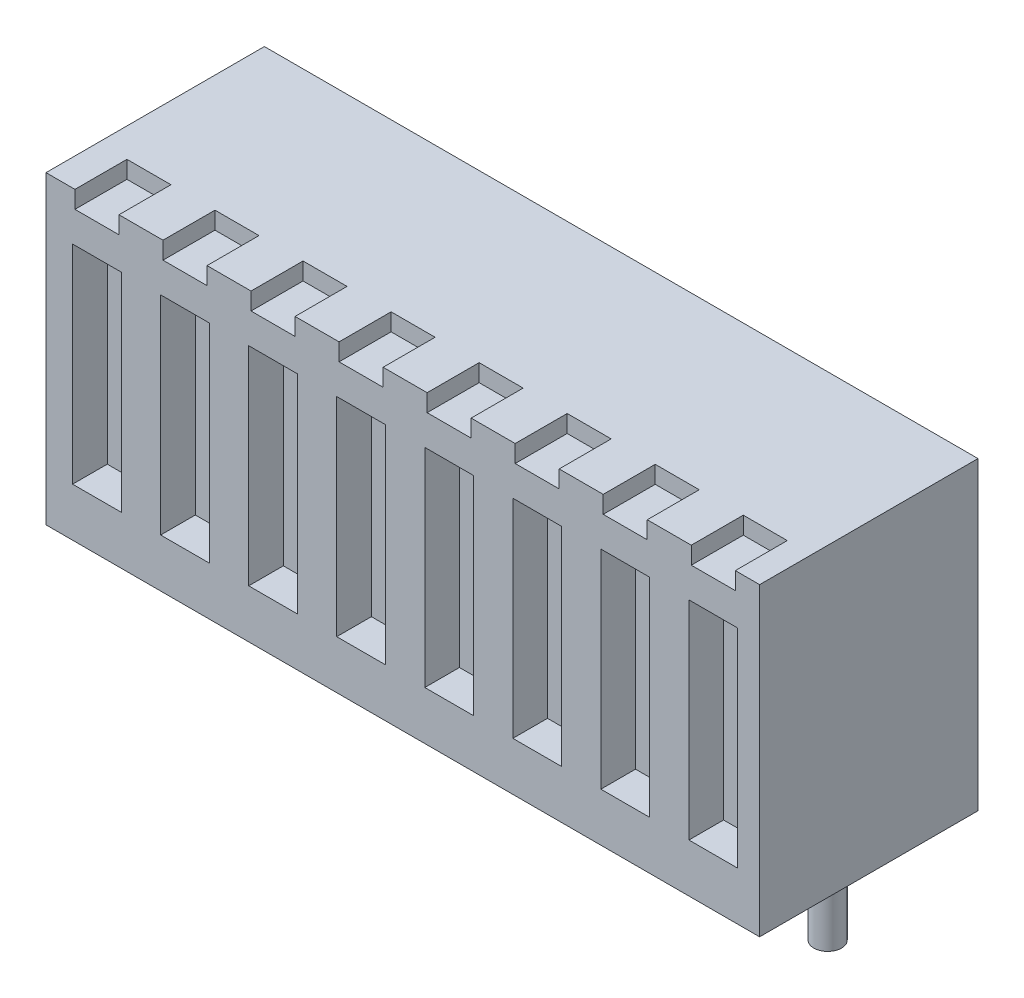
from build123d import *

# Parameters (mm, degrees)
SKETCH2_W           = 20.586666666
SKETCH2_H           = 6.3
BOSS_EXTRUDE1_DEPTH = 8.8
SKETCH3_R           = 0.4
BOSS_EXTRUDE2_DEPTH = 2.4
SKETCH4_W           = 1.405361948
SKETCH4_H           = 6
CUT_EXTRUDE1_DEPTH  = 1
SKETCH5_W           = 1.27
SKETCH5_H           = 1.5
CUT_EXTRUDE2_DEPTH  = 0.5
LPATTERN1_COUNT     = 8
LPATTERN1_PITCH     = 2.54


with BuildPart() as part:
    # Sketch2 → Boss-Extrude1 (new body)
    with BuildSketch(Plane(origin=(0, 0, 0), x_dir=(1, 0, 0), z_dir=(0, 1, 0))):
        Rectangle(SKETCH2_W, SKETCH2_H)
    extrude(amount=BOSS_EXTRUDE1_DEPTH)

    # Sketch3 → Boss-Extrude2 (add)
    with BuildSketch(Plane.XZ):
        with Locations((-8.823333333, -0.15)):
            Circle(SKETCH3_R)
    boss_extrude2 = extrude(amount=BOSS_EXTRUDE2_DEPTH)

    # Sketch4 → Cut-Extrude1 (cut)
    with BuildSketch(Plane.XY.offset(3.15)):
        with Locations((-8.823333333, 4.4)):
            Rectangle(SKETCH4_W, SKETCH4_H)
    cut_extrude1 = extrude(amount=-CUT_EXTRUDE1_DEPTH, mode=Mode.SUBTRACT)

    # Sketch5 → Cut-Extrude2 (cut)
    with BuildSketch(Plane(origin=(0, 8.8, 0), x_dir=(1, 0, 0), z_dir=(0, 1, 0))):
        with Locations((-8.823333333, -2.4)):
            Rectangle(SKETCH5_W, SKETCH5_H)
    cut_extrude2 = extrude(amount=-CUT_EXTRUDE2_DEPTH, mode=Mode.SUBTRACT)

    # LPattern1: Boss-Extrude2, Cut-Extrude1, Cut-Extrude2 ×8
    with Locations(*[(i * LPATTERN1_PITCH, 0, 0) for i in range(1, LPATTERN1_COUNT)]):
        add(boss_extrude2)
        add(cut_extrude1, mode=Mode.SUBTRACT)
        add(cut_extrude2, mode=Mode.SUBTRACT)


solid = part.part
